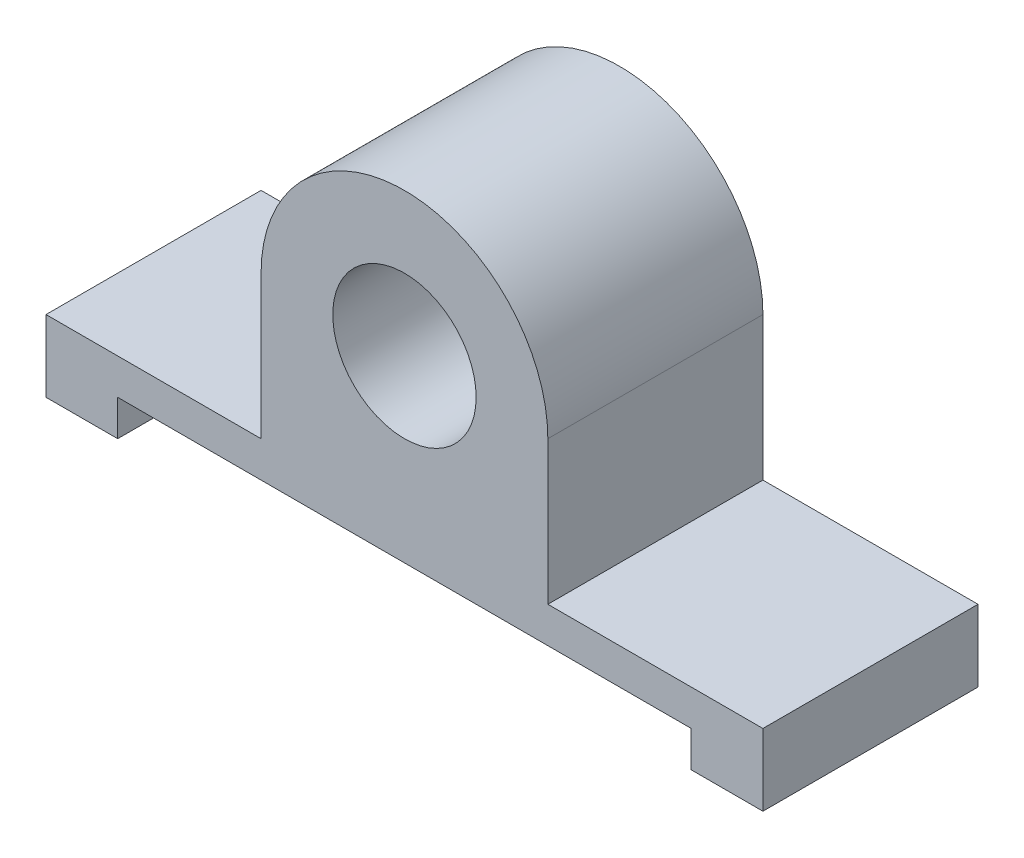
from build123d import *

# Parameters (mm, degrees)
SKETCH1_R           = 10
BOSS_EXTRUDE1_DEPTH = 30


with BuildPart() as part:
    # Sketch1 → Boss-Extrude1 (new body)
    with BuildSketch(Plane.XY):
        with BuildLine():
            Line((-38.125206472, -20.755714087), (41.874793528, -20.755714087))
            Line((41.874793528, -20.755714087), (41.874793528, -25.755714087))
            Line((41.874793528, -25.755714087), (51.874793528, -25.755714087))
            Line((51.874793528, -25.755714087), (51.874793528, -15.755714087))
            Line((51.874793528, -15.755714087), (21.874793528, -15.755714087))
            Line((21.874793528, -15.755714087), (21.874793528, 4.244285913))
            ThreePointArc((21.874793528, 4.244285913), (1.874793528, 24.244285913), (-18.125206472, 4.244285913))
            Line((-18.125206472, 4.244285913), (-18.125206472, -15.755714087))
            Line((-18.125206472, -15.755714087), (-48.125206472, -15.755714087))
            Line((-48.125206472, -15.755714087), (-48.125206472, -25.755714087))
            Line((-48.125206472, -25.755714087), (-38.125206472, -25.755714087))
            Line((-38.125206472, -25.755714087), (-38.125206472, -20.755714087))
        make_face()
        with Locations((1.874793528, 4.244285913)):
            Circle(SKETCH1_R, mode=Mode.SUBTRACT)
    extrude(amount=BOSS_EXTRUDE1_DEPTH)


solid = part.part
